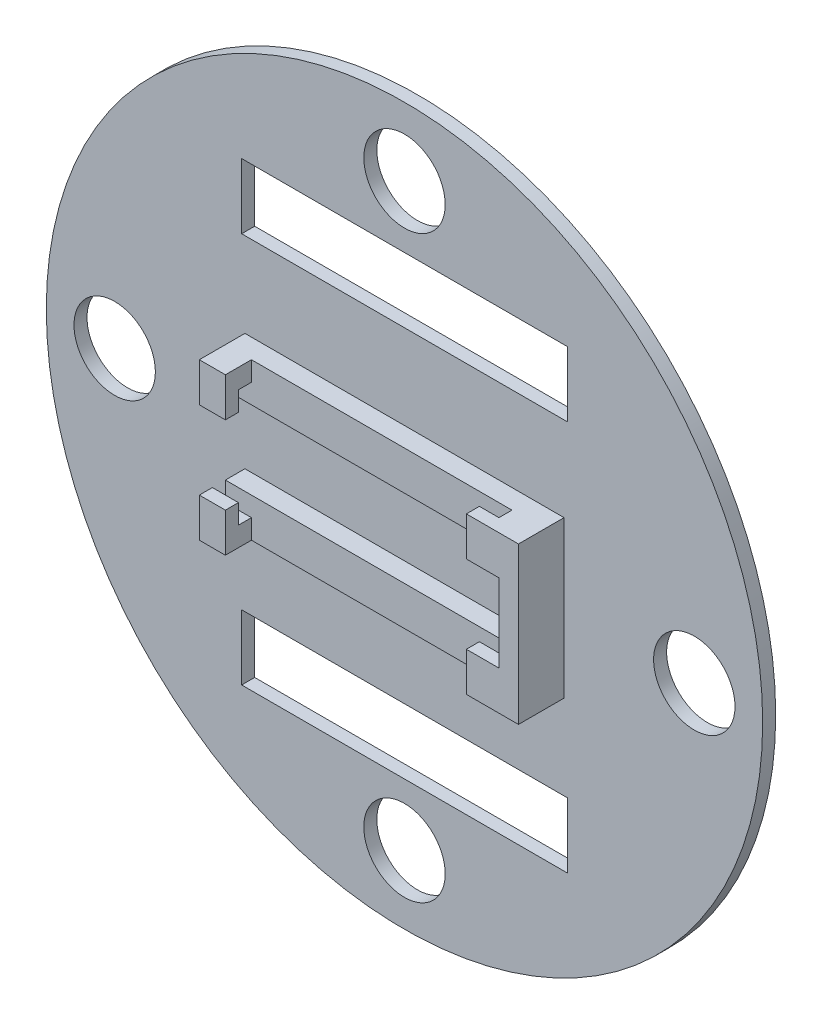
from build123d import *

# Parameters (mm, degrees)
SKETCH4_R            = 59
BOSS_EXTRUDE3_DEPTH  = 2
SKETCH5_R            = 1.375
BOSS_EXTRUDE5_DEPTH  = 7
SKETCH8_R            = 2.375
BOSS_EXTRUDE6_DEPTH  = 2
BOSS_EXTRUDE7_DEPTH  = 18
SKETCH10_R           = 7.5
CUT_EXTRUDE1_DEPTH   = 18
SKETCH12_R           = 57.5
CUT_EXTRUDE2_DEPTH   = 5
CUT_EXTRUDE3_DEPTH   = 5.5
SKETCH14_R           = 44.428135616
CUT_EXTRUDE4_DEPTH   = 32
BOSS_EXTRUDE8_DEPTH  = 3
BOSS_EXTRUDE9_DEPTH  = 2
SKETCH18_W           = 40
SKETCH18_H           = 24
CUT_EXTRUDE5_DEPTH   = 2
SKETCH19_W           = 4
SKETCH19_H           = 6
SKETCH19_W_2         = 8
SKETCH19_H_2         = 24
BOSS_EXTRUDE10_DEPTH = 2
SKETCH20_R           = 71.034408428
SKETCH20_R_2         = 50.972397724
CUT_EXTRUDE6_DEPTH   = 57
SKETCH21_R           = 79.144233261
SKETCH21_R_2         = 57
CUT_EXTRUDE8_DEPTH   = 57
BOSS_EXTRUDE11_DEPTH = 22
SKETCH24_R           = 89.588110905
SKETCH24_R_2         = 57
CUT_EXTRUDE12_DEPTH  = 75
SKETCH25_R           = 63.08525578
SKETCH25_R_2         = 55
CUT_EXTRUDE13_DEPTH  = 10
SKETCH26_R           = 62.71577626
SKETCH26_R_2         = 55
CUT_EXTRUDE14_DEPTH  = 43
SKETCH27_R           = 8.628716001
SKETCH27_R_2         = 7.77122145
SKETCH27_R_3         = 11.532169803
SKETCH27_R_4         = 7.052668864
CUT_EXTRUDE15_DEPTH  = 22
SKETCH28_R           = 55
BOSS_EXTRUDE12_DEPTH = 2
SKETCH29_W           = 5
SKETCH29_H           = 12
CUT_EXTRUDE16_DEPTH  = 3
SKETCH30_R           = 6.25
CUT_EXTRUDE17_DEPTH  = 3
SKETCH31_W           = 50
SKETCH31_H           = 10
CUT_EXTRUDE18_DEPTH  = 3


with BuildPart() as part:
    # Sketch4 → Boss-Extrude3 (new body)
    with BuildSketch(Plane.XY):
        Circle(SKETCH4_R)
    extrude(amount=BOSS_EXTRUDE3_DEPTH)

    # Sketch5 → Boss-Extrude5 (add)
    with BuildSketch(Plane.XY.offset(2)):
        with Locations((-22.5, 27.5)):
            Circle(SKETCH5_R)
        with Locations((22.5, 27.5)):
            Circle(SKETCH5_R)
        with Locations((22.5, -27.5)):
            Circle(SKETCH5_R)
        with Locations((-22.5, -27.5)):
            Circle(SKETCH5_R)
    extrude(amount=BOSS_EXTRUDE5_DEPTH)

    # Sketch8 → Boss-Extrude6 (add)
    with BuildSketch(Plane.XY.offset(2)):
        with Locations((-22.5, 27.5)):
            Circle(SKETCH8_R)
        with Locations((22.5, 27.5)):
            Circle(SKETCH8_R)
        with Locations((-22.5, -27.5)):
            Circle(SKETCH8_R)
        with Locations((22.5, -27.5)):
            Circle(SKETCH8_R)
    extrude(amount=BOSS_EXTRUDE6_DEPTH)

    # Sketch9 → Boss-Extrude7 (add)
    with BuildSketch(Plane.XY.offset(2)):
        with BuildLine():
            ThreePointArc((-4.745762712, 55.798546005), (0, 56), (4.745762712, 55.798546005))
            Line((4.745762712, 55.798546005), (5, 58.787753827))
            ThreePointArc((5, 58.787753827), (0, 59), (-5, 58.787753827))
            Line((-5, 58.787753827), (-4.745762712, 55.798546005))
        make_face()
        with BuildLine():
            Line((-55.798546005, 4.745762712), (-58.787753827, 5))
            ThreePointArc((-58.787753827, 5), (-59, 0), (-58.787753827, -5))
            Line((-58.787753827, -5), (-55.798546005, -4.745762712))
            ThreePointArc((-55.798546005, -4.745762712), (-56, 0), (-55.798546005, 4.745762712))
        make_face()
        with BuildLine():
            ThreePointArc((58.787753827, -5), (59, 0), (58.787753827, 5))
            Line((58.787753827, 5), (55.798546005, 4.745762712))
            ThreePointArc((55.798546005, 4.745762712), (56, 0), (55.798546005, -4.745762712))
            Line((55.798546005, -4.745762712), (58.787753827, -5))
        make_face()
        with BuildLine():
            ThreePointArc((-4.745762712, -55.798546005), (0, -56), (4.745762712, -55.798546005))
            Line((4.745762712, -55.798546005), (5, -58.787753827))
            ThreePointArc((5, -58.787753827), (0, -59), (-5, -58.787753827))
            Line((-5, -58.787753827), (-4.745762712, -55.798546005))
        make_face()
    extrude(amount=BOSS_EXTRUDE7_DEPTH)

    # Sketch10 → Cut-Extrude1 (cut)
    with BuildSketch(Plane.XY.offset(2)):
        with Locations((-40, 0)):
            Circle(SKETCH10_R)
    extrude(amount=-CUT_EXTRUDE1_DEPTH, mode=Mode.SUBTRACT)

    # Sketch12 → Cut-Extrude2 (cut)
    with BuildSketch(Plane.XY.offset(20)):
        Circle(SKETCH12_R)
    extrude(amount=-CUT_EXTRUDE2_DEPTH, mode=Mode.SUBTRACT)

    # Sketch13 → Cut-Extrude3 (cut)
    with BuildSketch(Plane(origin=(0, 0, 0), x_dir=(-1, 0, 0), z_dir=(0, 0, -1))):
        with BuildLine():
            Line((-57.243329786, 4.868644068), (-58.787753827, 5))
            ThreePointArc((-58.787753827, 5), (-59, 0), (-58.787753827, -5))
            Line((-58.787753827, -5), (-57.243329786, -4.868644068))
            ThreePointArc((-57.243329786, -4.868644068), (-57.45, 0), (-57.243329786, 4.868644068))
        make_face()
        with BuildLine():
            ThreePointArc((5, 58.787753827), (0, 59), (-5, 58.787753827))
            Line((-5, 58.787753827), (-4.868644068, 57.243329786))
            ThreePointArc((-4.868644068, 57.243329786), (0, 57.45), (4.868644068, 57.243329786))
            Line((4.868644068, 57.243329786), (5, 58.787753827))
        make_face()
        with BuildLine():
            Line((-4.868644068, -57.243329786), (-5, -58.787753827))
            ThreePointArc((-5, -58.787753827), (0, -59), (5, -58.787753827))
            Line((5, -58.787753827), (4.868644068, -57.243329786))
            ThreePointArc((4.868644068, -57.243329786), (0, -57.45), (-4.868644068, -57.243329786))
        make_face()
        with BuildLine():
            ThreePointArc((58.787753827, -5), (59, 0), (58.787753827, 5))
            Line((58.787753827, 5), (57.243329786, 4.868644068))
            ThreePointArc((57.243329786, 4.868644068), (57.45, 0), (57.243329786, -4.868644068))
            Line((57.243329786, -4.868644068), (58.787753827, -5))
        make_face()
    extrude(amount=-CUT_EXTRUDE3_DEPTH, mode=Mode.SUBTRACT)

    # Sketch14 → Cut-Extrude4 (cut)
    with BuildSketch(Plane.XY.offset(2)):
        Circle(SKETCH14_R)
    extrude(amount=CUT_EXTRUDE4_DEPTH, mode=Mode.SUBTRACT)

    # Sketch15 → Boss-Extrude8 (add)
    with BuildSketch(Plane.XY.offset(2)):
        Polygon((21.5, -6), (21.5, 6), (-24.5, 6), (-24.5, 12), (24.5, 12), (24.5, -12), (-24.5, -12), (-24.5, -6), align=None)
    extrude(amount=BOSS_EXTRUDE8_DEPTH)

    # Sketch17 → Boss-Extrude9 (add)
    with BuildSketch(Plane.XY.offset(5)):
        Polygon((21.5, -9), (-21.5, -9), (-24.5, -9), (-24.5, -12), (24.5, -12), (24.5, 12), (-24.5, 12), (-24.5, 9), (-21.5, 9), (21.5, 9), align=None)
    extrude(amount=BOSS_EXTRUDE9_DEPTH)

    # Sketch18 → Cut-Extrude5 (cut)
    with BuildSketch(Plane.XY.offset(7)):
        with Locations((-0.5, 0)):
            Rectangle(SKETCH18_W, SKETCH18_H)
    extrude(amount=-CUT_EXTRUDE5_DEPTH, mode=Mode.SUBTRACT)

    # Sketch19 → Boss-Extrude10 (add)
    with BuildSketch(Plane.XY.offset(7)):
        with Locations((-22.5, 9)):
            Rectangle(SKETCH19_W, SKETCH19_H)
        with Locations((-22.5, -9)):
            Rectangle(SKETCH19_W, SKETCH19_H)
        with Locations((20.5, 0)):
            Rectangle(SKETCH19_W_2, SKETCH19_H_2)
    extrude(amount=BOSS_EXTRUDE10_DEPTH)

    # Sketch20 → Cut-Extrude6 (cut)
    with BuildSketch(Plane.XY.offset(2)):
        Circle(SKETCH20_R)
        Circle(SKETCH20_R_2, mode=Mode.SUBTRACT)
    extrude(amount=CUT_EXTRUDE6_DEPTH, mode=Mode.SUBTRACT)

    # Sketch21 → Cut-Extrude8 (cut)
    with BuildSketch(Plane.XY.offset(2)):
        Circle(SKETCH21_R)
        Circle(SKETCH21_R_2, mode=Mode.SUBTRACT)
    extrude(amount=-CUT_EXTRUDE8_DEPTH, mode=Mode.SUBTRACT)

    # Sketch23 → Boss-Extrude11 (add)
    with BuildSketch(Plane.XY.offset(2)):
        with BuildLine():
            ThreePointArc((4.98087362, 56.781959265), (2.492821884, 56.945463727), (0, 57))
            ThreePointArc((0, 57), (-2.492821884, 56.945463727), (-4.98087362, 56.781959265))
            Line((-4.98087362, 56.781959265), (-4.631338629, 52.797260369))
            ThreePointArc((-4.631338629, 52.797260369), (0, 53), (4.631338629, 52.797260369))
            Line((4.631338629, 52.797260369), (4.98087362, 56.781959265))
        make_face()
        with BuildLine():
            ThreePointArc((57, 0), (56.945463727, 2.492821884), (56.781959265, 4.98087362))
            Line((56.781959265, 4.98087362), (52.797260369, 4.631338629))
            ThreePointArc((52.797260369, 4.631338629), (53, 0), (52.797260369, -4.631338629))
            Line((52.797260369, -4.631338629), (56.781959265, -4.98087362))
            ThreePointArc((56.781959265, -4.98087362), (56.945463727, -2.492821884), (57, 0))
        make_face()
        with BuildLine():
            ThreePointArc((-52.797260369, 4.631338629), (-53, 0), (-52.797260369, -4.631338629))
            Line((-52.797260369, -4.631338629), (-57, -5))
            Line((-57, -5), (-57, 5))
            Line((-57, 5), (-52.797260369, 4.631338629))
        make_face()
        with BuildLine():
            ThreePointArc((-4.631338629, -52.797260369), (0, -53), (4.631338629, -52.797260369))
            Line((4.631338629, -52.797260369), (5, -57))
            Line((5, -57), (-5, -57))
            Line((-5, -57), (-4.631338629, -52.797260369))
        make_face()
    extrude(amount=BOSS_EXTRUDE11_DEPTH)

    # Sketch24 → Cut-Extrude12 (cut)
    with BuildSketch(Plane.XY.offset(24)):
        Circle(SKETCH24_R)
        Circle(SKETCH24_R_2, mode=Mode.SUBTRACT)
    extrude(amount=-CUT_EXTRUDE12_DEPTH, mode=Mode.SUBTRACT)

    # Sketch25 → Cut-Extrude13 (cut)
    with BuildSketch(Plane.XY.offset(2)):
        Circle(SKETCH25_R)
        Circle(SKETCH25_R_2, mode=Mode.SUBTRACT)
    extrude(amount=-CUT_EXTRUDE13_DEPTH, mode=Mode.SUBTRACT)

    # Sketch26 → Cut-Extrude14 (cut)
    with BuildSketch(Plane(origin=(0, 0, 0), x_dir=(-1, 0, 0), z_dir=(0, 0, -1))):
        Circle(SKETCH26_R)
        Circle(SKETCH26_R_2, mode=Mode.SUBTRACT)
    extrude(amount=-CUT_EXTRUDE14_DEPTH, mode=Mode.SUBTRACT)

    # Sketch27 → Cut-Extrude15 (cut)
    with BuildSketch(Plane.XY.offset(24)):
        with Locations((-55, 0)):
            Circle(SKETCH27_R)
        with Locations((0, -55)):
            Circle(SKETCH27_R_2)
        with Locations((55, 0)):
            Circle(SKETCH27_R_3)
        with Locations((0, 53)):
            Circle(SKETCH27_R_4)
    extrude(amount=-CUT_EXTRUDE15_DEPTH, mode=Mode.SUBTRACT)

    # Sketch28 → Boss-Extrude12 (add)
    with BuildSketch(Plane.XY.offset(2)):
        Circle(SKETCH28_R)
    extrude(amount=-BOSS_EXTRUDE12_DEPTH)

    # Sketch29 → Cut-Extrude16 (cut)
    with BuildSketch(Plane.XY.offset(9)):
        with Locations((19, 0)):
            Rectangle(SKETCH29_W, SKETCH29_H)
    extrude(amount=-CUT_EXTRUDE16_DEPTH, mode=Mode.SUBTRACT)

    # Sketch30 → Cut-Extrude17 (cut)
    with BuildSketch(Plane.XY.offset(2)):
        with Locations((0, 44.5)):
            Circle(SKETCH30_R)
        with Locations((44.5, 0)):
            Circle(SKETCH30_R)
        with Locations((0, -44.5)):
            Circle(SKETCH30_R)
        with Locations((-44.5, 0)):
            Circle(SKETCH30_R)
    extrude(amount=-CUT_EXTRUDE17_DEPTH, mode=Mode.SUBTRACT)

    # Sketch31 → Cut-Extrude18 (cut)
    with BuildSketch(Plane.XY.offset(2)):
        with Locations((0, 30)):
            Rectangle(SKETCH31_W, SKETCH31_H)
        with Locations((0, -30)):
            Rectangle(SKETCH31_W, SKETCH31_H)
    extrude(amount=-CUT_EXTRUDE18_DEPTH, mode=Mode.SUBTRACT)


solid = part.part
